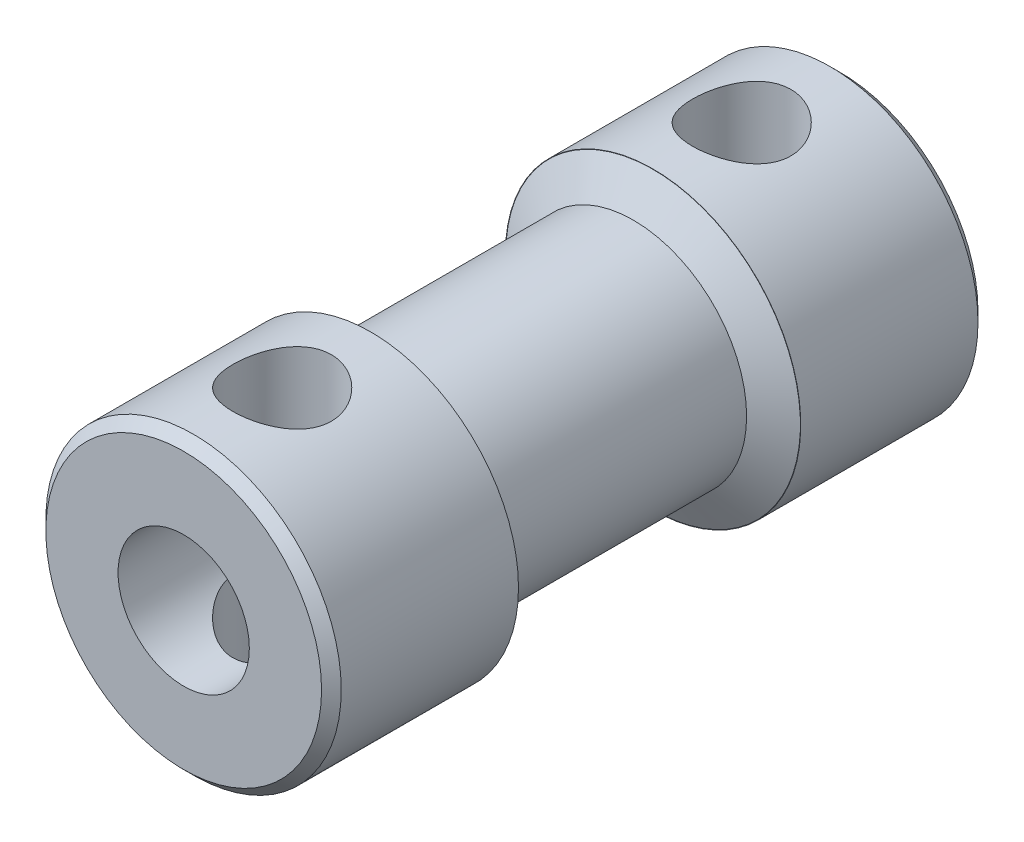
from build123d import *

# Parameters (mm, degrees)
SKICA8_R                 = 4.5
SKICA8_R_2               = 1.5
P_IDAT_VYSUNUT_M8_DEPTH  = 20
SKICA9_W                 = 8.6
SKICA9_H                 = 1.884529933
ZKOSEN_1_SIZE            = 0.6
ZKOSEN_1_SIZE2           = 1.039230485
ZKOSEN_2_SIZE            = 0.6
ZKOSEN_2_SIZE2           = 1.039230485
ZKOSEN_3_SIZE            = 0.3
SKICA10_R                = 1.5
ODEBRAT_VYSUNUT_M1_DEPTH = 10
SKICA11_R                = 2
ODEBRAT_VYSUNUT_M2_DEPTH = 10


with BuildPart() as part:
    # Skica8 → Přidat vysunutím8 (new body)
    with BuildSketch(Plane(origin=(23.8, 0, 0), x_dir=(1, 0, 0), z_dir=(0, 0, 1))):
        with Locations((-23.8, 0)):
            Circle(SKICA8_R)
        with Locations((-23.8, 0)):
            Circle(SKICA8_R_2, mode=Mode.SUBTRACT)
    extrude(amount=P_IDAT_VYSUNUT_M8_DEPTH)

    # Skica9 → Odebrat rotací1 (revolve, cut)
    with BuildSketch(Plane(origin=(0, 0, 0), x_dir=(0, 0, -1), z_dir=(1, 0, 0))):
        with Locations((-10, 4.392264967)):
            Rectangle(SKICA9_W, SKICA9_H)
    revolve(axis=Axis((0, 0, 0), (0, 0, 1)), mode=Mode.SUBTRACT)

    # Zkosení1
    zkosen_1_edges = [part.edges().sort_by_distance(p)[0] for p in [
        (0, -3.45, 5.7),
    ]]
    zkosen_1_side = [part.faces().sort_by_distance(p)[0] for p in [
        (0, -3.45, 10),
    ]]
    chamfer(zkosen_1_edges, length=ZKOSEN_1_SIZE, length2=ZKOSEN_1_SIZE2, reference=zkosen_1_side[0])

    # Zkosení2
    zkosen_2_edges = [part.edges().sort_by_distance(p)[0] for p in [
        (0, -3.45, 14.3),
    ]]
    zkosen_2_side = [part.faces().sort_by_distance(p)[0] for p in [
        (0, -3.45, 10.3),
    ]]
    chamfer(zkosen_2_edges, length=ZKOSEN_2_SIZE, length2=ZKOSEN_2_SIZE2, reference=zkosen_2_side[0])

    # Zkosení3
    zkosen_3_edges = [part.edges().sort_by_distance(p)[0] for p in [
        (-4.5, 0, 0),
        (-4.5, 0, 20),
    ]]
    chamfer(zkosen_3_edges, length=ZKOSEN_3_SIZE)

    # Skica10 → Odebrat vysunutím1 (cut, symmetric)
    with BuildSketch(Plane(origin=(0, 0, 0), x_dir=(1, 0, 0), z_dir=(0, 1, 0))):
        with Locations((0, -3)):
            Circle(SKICA10_R)
        with Locations((0, -17)):
            Circle(SKICA10_R)
    extrude(amount=ODEBRAT_VYSUNUT_M1_DEPTH, both=True, mode=Mode.SUBTRACT)

    # Skica11 → Odebrat vysunutím2 (cut)
    with BuildSketch(Plane.XY.offset(20)):
        Circle(SKICA11_R)
    extrude(amount=-ODEBRAT_VYSUNUT_M2_DEPTH, mode=Mode.SUBTRACT)


solid = part.part
